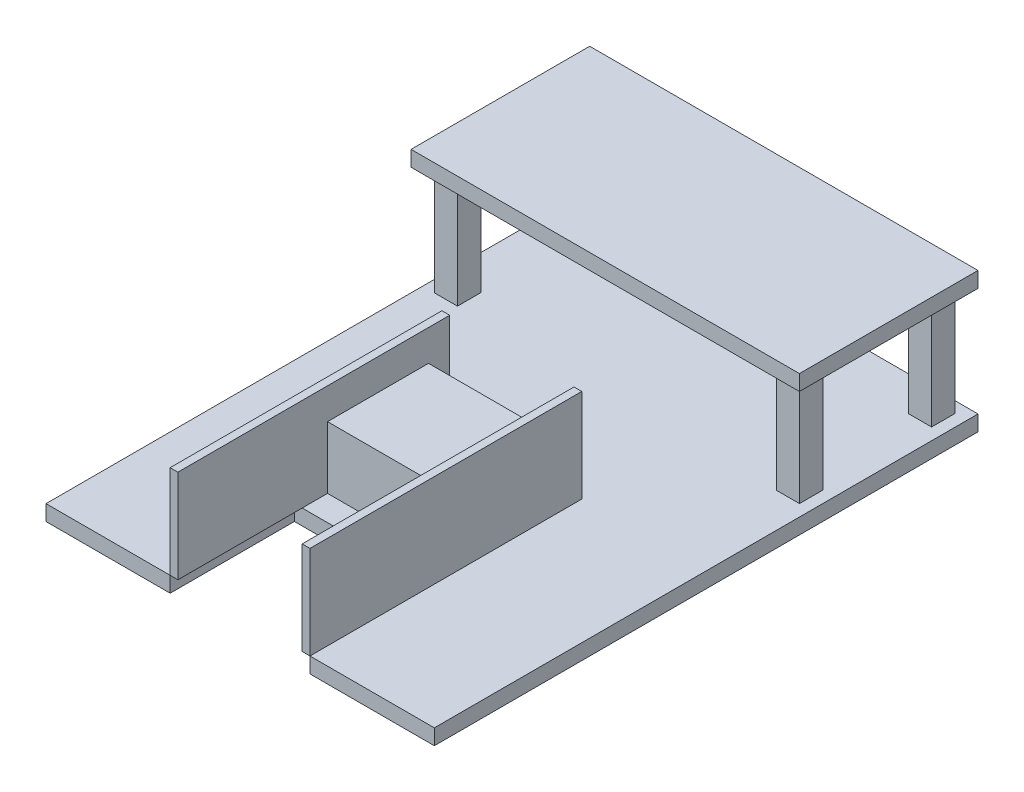
from build123d import *

# Parameters (mm, degrees)
BOSS_EXTRUDE1_DEPTH   = 10
SKETCH3_W             = 5
SKETCH3_H             = 175
BOSS_EXTRUDE3_DEPTH   = 60
BOSS_EXTRUDE3_2_DEPTH = 60
SKETCH4_W             = 80
SKETCH4_H             = 65
BOSS_EXTRUDE4_DEPTH   = 70
SKETCH4_W_2           = 14.818270304
SKETCH4_H_2           = 15
BOSS_EXTRUDE4_2_DEPTH = 70
BOSS_EXTRUDE4_3_DEPTH = 70
SKETCH4_W_3           = 14.818270303
BOSS_EXTRUDE4_4_DEPTH = 70
BOSS_EXTRUDE4_5_DEPTH = 70
SKETCH5_W             = 80
SKETCH5_H             = 65
CUT_EXTRUDE1_DEPTH    = 30
SKETCH6_W             = 250
SKETCH6_H             = 114.969361411
BOSS_EXTRUDE5_DEPTH   = 10
SKETCH7_W             = 89.480070442
SKETCH7_H             = 130.009753393
BOSS_EXTRUDE6_DEPTH   = 50
SKETCH8_W             = 77.480070442
SKETCH8_H             = 38
CUT_EXTRUDE4_DEPTH    = 246.280237845


with BuildPart() as part:
    # Sketch2 → Boss-Extrude1 (new body)
    with BuildSketch(Plane(origin=(0, 0, 0), x_dir=(1, 0, 0), z_dir=(0, 1, 0))):
        Polygon((125, 175), (-125, 175), (-125, -175), (-45.078787682, -175), (-45.078787682, -95), (44.921212318, -95), (44.921212318, -175), (44.965173676, -175), (125, -175), align=None)
    extrude(amount=BOSS_EXTRUDE1_DEPTH)

    # Sketch7 → Boss-Extrude6 (add)
    with BuildSketch(Plane.XZ):
        with Locations((2.744175311, -5.275361149)):
            Rectangle(SKETCH7_W, SKETCH7_H)
    extrude(amount=BOSS_EXTRUDE6_DEPTH)

    # Sketch8 → Cut-Extrude4 (cut, through all)
    with BuildSketch(Plane(origin=(0, 0, -70.280237845), x_dir=(-1, 0, 0), z_dir=(0, 0, -1))):
        with Locations((-2.744175311, -25)):
            Rectangle(SKETCH8_W, SKETCH8_H)
    extrude(amount=-CUT_EXTRUDE4_DEPTH, mode=Mode.SUBTRACT)


with BuildPart() as body_2:
    # Sketch3 → Boss-Extrude3 (new body)
    with BuildSketch(Plane(origin=(0, 10, 0), x_dir=(1, 0, 0), z_dir=(0, 1, 0))):
        with Locations((-42.578787682, -87.5)):
            Rectangle(SKETCH3_W, SKETCH3_H)
    extrude(amount=BOSS_EXTRUDE3_DEPTH)


with BuildPart() as body_3:
    # Sketch3 → Boss-Extrude3 2 (new body)
    with BuildSketch(Plane(origin=(0, 10, 0), x_dir=(1, 0, 0), z_dir=(0, 1, 0))):
        with Locations((42.421212318, -87.5)):
            Rectangle(SKETCH3_W, SKETCH3_H)
    extrude(amount=BOSS_EXTRUDE3_2_DEPTH)


with BuildPart() as body_4:
    # Sketch4 → Boss-Extrude4 (new body)
    with BuildSketch(Plane(origin=(0, 10, 0), x_dir=(1, 0, 0), z_dir=(0, 1, 0))):
        with Locations((-0.078787682, -46.182156377)):
            Rectangle(SKETCH4_W, SKETCH4_H)
    extrude(amount=BOSS_EXTRUDE4_DEPTH)

    # Sketch5 → Cut-Extrude1 (cut)
    with BuildSketch(Plane(origin=(0, 80, 0), x_dir=(1, 0, 0), z_dir=(0, 1, 0))):
        with Locations((-0.078787682, -46.182156377)):
            Rectangle(SKETCH5_W, SKETCH5_H)
    extrude(amount=-CUT_EXTRUDE1_DEPTH, mode=Mode.SUBTRACT)


with BuildPart() as body_5:
    # Sketch4 → Boss-Extrude4 2 (new body)
    with BuildSketch(Plane(origin=(0, 10, 0), x_dir=(1, 0, 0), z_dir=(0, 1, 0))):
        with Locations((-110, 160)):
            Rectangle(SKETCH4_W_2, SKETCH4_H_2)
    extrude(amount=BOSS_EXTRUDE4_2_DEPTH)



with BuildPart() as body_6:
    # Sketch4 → Boss-Extrude4 3 (new body)
    with BuildSketch(Plane(origin=(0, 10, 0), x_dir=(1, 0, 0), z_dir=(0, 1, 0))):
        with Locations((-110.057576569, 75.030638589)):
            Rectangle(SKETCH4_W_2, SKETCH4_H_2)
    extrude(amount=BOSS_EXTRUDE4_3_DEPTH)


with BuildPart() as body_7:
    # Sketch4 → Boss-Extrude4 4 (new body)
    with BuildSketch(Plane(origin=(0, 10, 0), x_dir=(1, 0, 0), z_dir=(0, 1, 0))):
        with Locations((109.933142223, 160.27452831)):
            Rectangle(SKETCH4_W_3, SKETCH4_H_2)
    extrude(amount=BOSS_EXTRUDE4_4_DEPTH)


with BuildPart() as body_8:
    # Sketch4 → Boss-Extrude4 5 (new body)
    with BuildSketch(Plane(origin=(0, 10, 0), x_dir=(1, 0, 0), z_dir=(0, 1, 0))):
        with Locations((110.111370806, 75.046426768)):
            Rectangle(SKETCH4_W_2, SKETCH4_H_2)
    extrude(amount=BOSS_EXTRUDE4_5_DEPTH)


with BuildPart() as body_5_1:
    add(body_5.part)

    add(body_6.part)  # Boss-Extrude5 merges body 6

    add(body_7.part)  # Boss-Extrude5 merges body 7

    add(body_8.part)  # Boss-Extrude5 merges body 8
    # Sketch6 → Boss-Extrude5 (add)
    with BuildSketch(Plane(origin=(0, 80, 0), x_dir=(1, 0, 0), z_dir=(0, 1, 0))):
        with Locations((0, 117.515319295)):
            Rectangle(SKETCH6_W, SKETCH6_H)
    extrude(amount=BOSS_EXTRUDE5_DEPTH)


solid = Compound([part.part, body_2.part, body_3.part, body_4.part, body_5_1.part])
